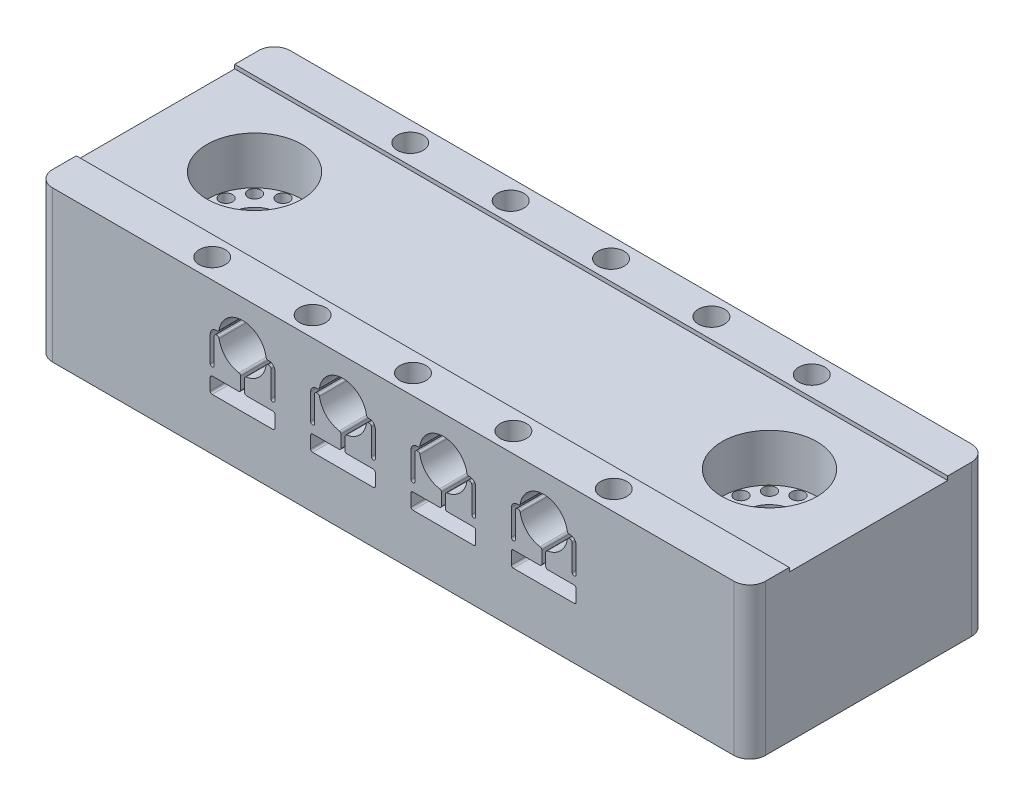
from build123d import *

# Parameters (mm, degrees)
SKETCH1_R                      = 3
SKETCH1_R_2                    = 0.815869739
BOSS_EXTRUDE1_DEPTH            = 19.05
SKETCH2_R                      = 6
CUT_EXTRUDE1_DEPTH             = 6.5
CUT_EXTRUDE2_DEPTH             = 31
LPATTERN1_COUNT                = 4
LPATTERN1_PITCH                = 12.671363488
M4X0_7_TAPPED_HOLE1_AT_2_COUNT = 2
M4X0_7_TAPPED_HOLE1_AT_2_PITCH = 25
LPATTERN2_COUNT                = 5
LPATTERN2_PITCH                = 12.671363488
SKETCH4_W                      = 90
SKETCH4_H                      = 20
CUT_EXTRUDE3_DEPTH             = 0.5
CUT_EXTRUDE4_START             = -6.547849
SKETCH7_R                      = 2.5
CUT_EXTRUDE4_DEPTH             = 6.547849
LPATTERN3_COUNT                = 4
LPATTERN3_PITCH                = 12.671363488


with BuildPart() as part:
    # Sketch1 → Boss-Extrude1 (new body)
    with BuildSketch(Plane(origin=(0, 0, 0), x_dir=(1, 0, 0), z_dir=(0, 1, 0))):
        with BuildLine():
            Line((-45, 13), (-45, -13))
            ThreePointArc((-45, -13), (-44.414213562, -14.414213562), (-43, -15))
            Line((-43, -15), (43, -15))
            ThreePointArc((43, -15), (44.414213562, -14.414213562), (45, -13))
            Line((45, -13), (45, 13))
            ThreePointArc((45, 13), (44.414213562, 14.414213562), (43, 15))
            Line((43, 15), (-43, 15))
            ThreePointArc((-43, 15), (-44.414213562, 14.414213562), (-45, 13))
        make_face()
        with Locations((-32.5, 0)):
            Circle(SKETCH1_R, mode=Mode.SUBTRACT)
        with Locations((32.5, 0)):
            Circle(SKETCH1_R, mode=Mode.SUBTRACT)
        with Locations((-31.184130261, 4.910892723)):
            Circle(SKETCH1_R_2, mode=Mode.SUBTRACT)
        with Locations((-33.815869739, 4.910892723)):
            Circle(SKETCH1_R_2, mode=Mode.SUBTRACT)
        with Locations((-36.095022984, 3.595022984)):
            Circle(SKETCH1_R_2, mode=Mode.SUBTRACT)
        with Locations((-37.410892723, 1.315869739)):
            Circle(SKETCH1_R_2, mode=Mode.SUBTRACT)
        with Locations((-37.410892723, -1.315869739)):
            Circle(SKETCH1_R_2, mode=Mode.SUBTRACT)
        with Locations((-36.095022984, -3.595022984)):
            Circle(SKETCH1_R_2, mode=Mode.SUBTRACT)
        with Locations((-33.815869739, -4.910892723)):
            Circle(SKETCH1_R_2, mode=Mode.SUBTRACT)
        with Locations((-31.184130261, -4.910892723)):
            Circle(SKETCH1_R_2, mode=Mode.SUBTRACT)
        with Locations((-28.904977016, -3.595022984)):
            Circle(SKETCH1_R_2, mode=Mode.SUBTRACT)
        with Locations((-27.589107277, -1.315869739)):
            Circle(SKETCH1_R_2, mode=Mode.SUBTRACT)
        with Locations((-27.589107277, 1.315869739)):
            Circle(SKETCH1_R_2, mode=Mode.SUBTRACT)
        with Locations((-28.904977016, 3.595022984)):
            Circle(SKETCH1_R_2, mode=Mode.SUBTRACT)
        with Locations((31.184130261, 4.910892723)):
            Circle(SKETCH1_R_2, mode=Mode.SUBTRACT)
        with Locations((33.815869739, 4.910892723)):
            Circle(SKETCH1_R_2, mode=Mode.SUBTRACT)
        with Locations((36.095022984, 3.595022984)):
            Circle(SKETCH1_R_2, mode=Mode.SUBTRACT)
        with Locations((37.410892723, 1.315869739)):
            Circle(SKETCH1_R_2, mode=Mode.SUBTRACT)
        with Locations((37.410892723, -1.315869739)):
            Circle(SKETCH1_R_2, mode=Mode.SUBTRACT)
        with Locations((36.095022984, -3.595022984)):
            Circle(SKETCH1_R_2, mode=Mode.SUBTRACT)
        with Locations((33.815869739, -4.910892723)):
            Circle(SKETCH1_R_2, mode=Mode.SUBTRACT)
        with Locations((31.184130261, -4.910892723)):
            Circle(SKETCH1_R_2, mode=Mode.SUBTRACT)
        with Locations((28.904977016, -3.595022984)):
            Circle(SKETCH1_R_2, mode=Mode.SUBTRACT)
        with Locations((27.589107277, -1.315869739)):
            Circle(SKETCH1_R_2, mode=Mode.SUBTRACT)
        with Locations((27.589107277, 1.315869739)):
            Circle(SKETCH1_R_2, mode=Mode.SUBTRACT)
        with Locations((28.904977016, 3.595022984)):
            Circle(SKETCH1_R_2, mode=Mode.SUBTRACT)
    extrude(amount=BOSS_EXTRUDE1_DEPTH)

    # Sketch2 → Cut-Extrude1 (cut)
    with BuildSketch(Plane(origin=(0, 19.05, 0), x_dir=(1, 0, 0), z_dir=(0, 1, 0))):
        with Locations((32.5, 0)):
            Circle(SKETCH2_R)
        with Locations((-32.5, 0)):
            Circle(SKETCH2_R)
    extrude(amount=-CUT_EXTRUDE1_DEPTH, mode=Mode.SUBTRACT)

    # Sketch3 → Cut-Extrude2 (cut, through all)
    with BuildSketch(Plane.XY.offset(15)):
        with BuildLine():
            Line((-22.218353377, 13.8), (-22.342726976, 13.8))
            ThreePointArc((-22.342726976, 13.8), (-22.873057062, 13.580330086), (-23.092726976, 13.05))
            Line((-23.092726976, 13.05), (-23.092726976, 9.8))
            ThreePointArc((-23.092726976, 9.8), (-22.842726976, 9.55), (-22.592726976, 9.8))
            Line((-22.592726976, 9.8), (-22.592726976, 13.05))
            ThreePointArc((-22.592726976, 13.05), (-22.519503672, 13.226776695), (-22.342726976, 13.3))
            Line((-22.342726976, 13.3), (-22.218353377, 13.3))
            ThreePointArc((-22.218353377, 13.3), (-22.055742468, 13.239888631), (-21.971329673, 13.088461538))
            ThreePointArc((-21.971329673, 13.088461538), (-21.128365576, 11.428679656), (-19.468583694, 10.585715559))
            ThreePointArc((-19.468583694, 10.585715559), (-19.317156601, 10.501302764), (-19.257045232, 10.338691855))
            Line((-19.257045232, 10.338691855), (-19.257045232, 8.8))
            ThreePointArc((-19.257045232, 8.8), (-19.330268537, 8.623223305), (-19.507045232, 8.55))
            Line((-19.507045232, 8.55), (-22.842726976, 8.55))
            ThreePointArc((-22.842726976, 8.55), (-23.019503672, 8.476776695), (-23.092726976, 8.3))
            Line((-23.092726976, 8.3), (-23.092726976, 6.797848452))
            ThreePointArc((-23.092726976, 6.797848452), (-23.019503672, 6.621071757), (-22.842726976, 6.547848452))
            Line((-22.842726976, 6.547848452), (-15.171363488, 6.547848452))
            ThreePointArc((-15.171363488, 6.547848452), (-14.994586793, 6.621071757), (-14.921363488, 6.797848452))
            Line((-14.921363488, 6.797848452), (-14.921363488, 8.3))
            ThreePointArc((-14.921363488, 8.3), (-14.994586793, 8.476776695), (-15.171363488, 8.55))
            Line((-15.171363488, 8.55), (-18.507045232, 8.55))
            ThreePointArc((-18.507045232, 8.55), (-18.683821927, 8.623223305), (-18.757045232, 8.8))
            Line((-18.757045232, 8.8), (-18.757045232, 10.338691855))
            ThreePointArc((-18.757045232, 10.338691855), (-18.696933863, 10.501302764), (-18.545506771, 10.585715559))
            ThreePointArc((-18.545506771, 10.585715559), (-16.885724889, 11.428679656), (-16.042760791, 13.088461538))
            ThreePointArc((-16.042760791, 13.088461538), (-15.958347996, 13.239888631), (-15.795737087, 13.3))
            Line((-15.795737087, 13.3), (-15.671363488, 13.3))
            ThreePointArc((-15.671363488, 13.3), (-15.494586793, 13.226776695), (-15.421363488, 13.05))
            Line((-15.421363488, 13.05), (-15.421363488, 9.8))
            ThreePointArc((-15.421363488, 9.8), (-15.171363488, 9.55), (-14.921363488, 9.8))
            Line((-14.921363488, 9.8), (-14.921363488, 13.05))
            ThreePointArc((-14.921363488, 13.05), (-15.141033402, 13.580330086), (-15.671363488, 13.8))
            Line((-15.671363488, 13.8), (-15.795737087, 13.8))
            ThreePointArc((-15.795737087, 13.8), (-15.958347996, 13.860111369), (-16.042760791, 14.011538462))
            ThreePointArc((-16.042760791, 14.011538462), (-19.007045232, 16.55), (-21.971329673, 14.011538462))
            ThreePointArc((-21.971329673, 14.011538462), (-22.055742468, 13.860111369), (-22.218353377, 13.8))
        make_face()
    cut_extrude2 = extrude(amount=-CUT_EXTRUDE2_DEPTH, mode=Mode.SUBTRACT)

    # LPattern1: Cut-Extrude2 ×4
    with Locations(*[(i * LPATTERN1_PITCH, 0, 0) for i in range(1, LPATTERN1_COUNT)]):
        add(cut_extrude2, mode=Mode.SUBTRACT)

    # Sketch6 → M4x0.7 Tapped Hole1 (revolve, cut)
    with BuildSketch(Plane(origin=(-25.342726976, 19.05, 12.5), x_dir=(0, 0, 1), z_dir=(1, 0, 0))):
        Polygon((0, 0), (0, 11.091420021), (1.65, 10.1), (1.65, 0), align=None)
    m4x0_7_tapped_hole1 = revolve(axis=Axis((-25.342726976, 25.4, 12.5), (0, -1, 0)), mode=Mode.SUBTRACT)

    # M4x0.7 Tapped Hole1 at 2: M4x0.7 Tapped Hole1 ×2
    with Locations(*[(0, 0, -i * M4X0_7_TAPPED_HOLE1_AT_2_PITCH) for i in range(1, M4X0_7_TAPPED_HOLE1_AT_2_COUNT)]):
        add(m4x0_7_tapped_hole1, mode=Mode.SUBTRACT)

    # LPattern2: M4x0.7 Tapped Hole1 ×5
    with Locations(*[(i * LPATTERN2_PITCH, 0, 0) for i in range(1, LPATTERN2_COUNT)]):
        add(m4x0_7_tapped_hole1, mode=Mode.SUBTRACT)

    # LPattern2 copy 1 sketch → LPattern2 copy 1 (revolve, cut)
    with BuildSketch(Plane(origin=(-12.671363488, 19.05, -12.5), x_dir=(0, 0, 1), z_dir=(1, 0, 0))):
        Polygon((0, 0), (0, 11.091420021), (1.65, 10.1), (1.65, 0), align=None)
    revolve(axis=Axis((-12.671363488, 25.4, -12.5), (0, -1, 0)), mode=Mode.SUBTRACT)

    # LPattern2 copy 2 sketch → LPattern2 copy 2 (revolve, cut)
    with BuildSketch(Plane(origin=(0, 19.05, -12.5), x_dir=(0, 0, 1), z_dir=(1, 0, 0))):
        Polygon((0, 0), (0, 11.091420021), (1.65, 10.1), (1.65, 0), align=None)
    revolve(axis=Axis((0, 25.4, -12.5), (0, -1, 0)), mode=Mode.SUBTRACT)

    # LPattern2 copy 3 sketch → LPattern2 copy 3 (revolve, cut)
    with BuildSketch(Plane(origin=(12.671363488, 19.05, -12.5), x_dir=(0, 0, 1), z_dir=(1, 0, 0))):
        Polygon((0, 0), (0, 11.091420021), (1.65, 10.1), (1.65, 0), align=None)
    revolve(axis=Axis((12.671363488, 25.4, -12.5), (0, -1, 0)), mode=Mode.SUBTRACT)

    # LPattern2 copy 4 sketch → LPattern2 copy 4 (revolve, cut)
    with BuildSketch(Plane(origin=(25.342726976, 19.05, -12.5), x_dir=(0, 0, 1), z_dir=(1, 0, 0))):
        Polygon((0, 0), (0, 11.091420021), (1.65, 10.1), (1.65, 0), align=None)
    revolve(axis=Axis((25.342726976, 25.4, -12.5), (0, -1, 0)), mode=Mode.SUBTRACT)

    # Sketch4 → Cut-Extrude3 (cut)
    with BuildSketch(Plane(origin=(0, 19.05, 0), x_dir=(1, 0, 0), z_dir=(0, 1, 0))):
        Rectangle(SKETCH4_W, SKETCH4_H)
    extrude(amount=-CUT_EXTRUDE3_DEPTH, mode=Mode.SUBTRACT)

    # Sketch7 → Cut-Extrude4 (cut)
    with BuildSketch(Plane.XZ.offset(CUT_EXTRUDE4_START)):
        with Locations((-19.007045232, 5)):
            Circle(SKETCH7_R)
        with Locations((-19.007045232, -5)):
            Circle(SKETCH7_R)
    cut_extrude4 = extrude(amount=CUT_EXTRUDE4_DEPTH, mode=Mode.SUBTRACT)

    # LPattern3: Cut-Extrude4 ×4
    with Locations(*[(i * LPATTERN3_PITCH, 0, 0) for i in range(1, LPATTERN3_COUNT)]):
        add(cut_extrude4, mode=Mode.SUBTRACT)


solid = part.part
